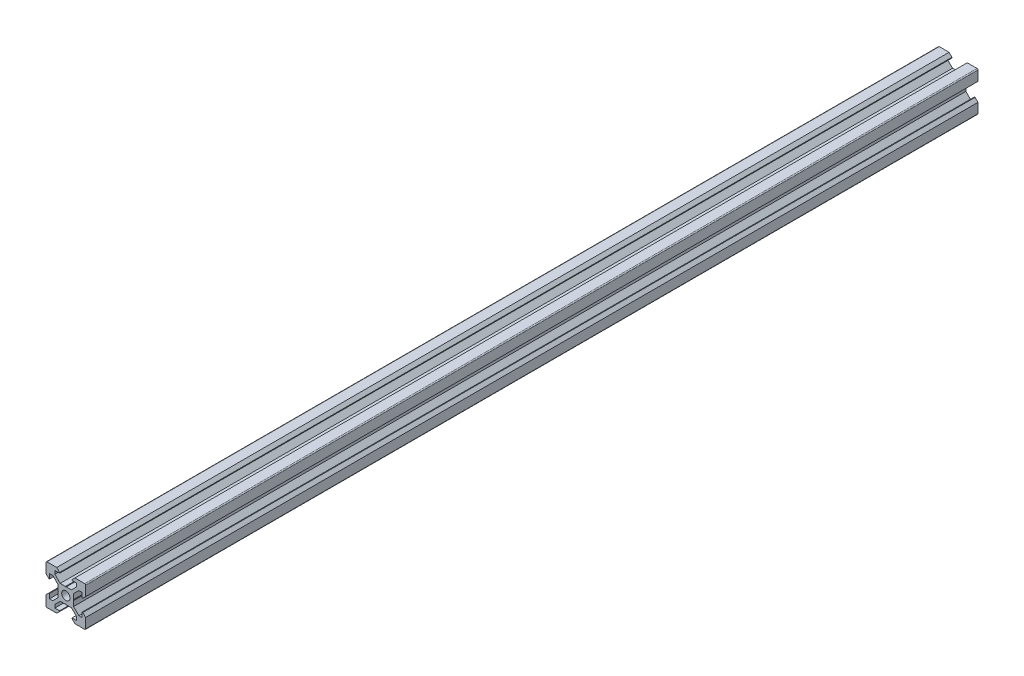
from build123d import *

# Parameters (mm, degrees)
SKETCH1_R           = 2.1
BOSS_EXTRUDE1_DEPTH = 450


with BuildPart() as part:
    # Sketch1 → Boss-Extrude1 (new body)
    with BuildSketch(Plane.XY):
        with BuildLine():
            Line((4.58, -10), (9.5, -10))
            ThreePointArc((9.5, -10), (9.853553391, -9.853553391), (10, -9.5))
            Line((10, -9.5), (10, -4.58))
            Line((10, -4.58), (8.545, -3.125))
            Line((8.545, -3.125), (8.2, -3.125))
            Line((8.2, -3.125), (8.2, -5.5))
            Line((8.2, -5.5), (6.560660172, -5.5))
            Line((6.560660172, -5.5), (3.9, -2.839339828))
            Line((3.9, -2.839339828), (3.9, -0.21))
            Line((3.9, -0.21), (3.69, 0))
            Line((3.69, 0), (3.9, 0.21))
            Line((3.9, 0.21), (3.9, 2.839339828))
            Line((3.9, 2.839339828), (6.560660172, 5.5))
            Line((6.560660172, 5.5), (8.2, 5.5))
            Line((8.2, 5.5), (8.2, 3.125))
            Line((8.2, 3.125), (8.545, 3.125))
            Line((8.545, 3.125), (10, 4.58))
            Line((10, 4.58), (10, 9.5))
            ThreePointArc((10, 9.5), (9.853553391, 9.853553391), (9.5, 10))
            Line((9.5, 10), (4.58, 10))
            Line((4.58, 10), (3.125, 8.545))
            Line((3.125, 8.545), (3.125, 8.2))
            Line((3.125, 8.2), (5.5, 8.2))
            Line((5.5, 8.2), (5.5, 6.560660172))
            Line((5.5, 6.560660172), (2.839339828, 3.9))
            Line((2.839339828, 3.9), (0.21, 3.9))
            Line((0.21, 3.9), (0, 3.69))
            Line((0, 3.69), (-0.21, 3.9))
            Line((-0.21, 3.9), (-2.839339828, 3.9))
            Line((-2.839339828, 3.9), (-5.5, 6.560660172))
            Line((-5.5, 6.560660172), (-5.5, 8.2))
            Line((-5.5, 8.2), (-3.125, 8.2))
            Line((-3.125, 8.2), (-3.125, 8.545))
            Line((-3.125, 8.545), (-4.58, 10))
            Line((-4.58, 10), (-9.5, 10))
            ThreePointArc((-9.5, 10), (-9.853553391, 9.853553391), (-10, 9.5))
            Line((-10, 9.5), (-10, 4.58))
            Line((-10, 4.58), (-8.545, 3.125))
            Line((-8.545, 3.125), (-8.2, 3.125))
            Line((-8.2, 3.125), (-8.2, 5.5))
            Line((-8.2, 5.5), (-6.560660172, 5.5))
            Line((-6.560660172, 5.5), (-3.9, 2.839339828))
            Line((-3.9, 2.839339828), (-3.9, 0.21))
            Line((-3.9, 0.21), (-3.69, 0))
            Line((-3.69, 0), (-3.9, -0.21))
            Line((-3.9, -0.21), (-3.9, -2.839339828))
            Line((-3.9, -2.839339828), (-6.560660172, -5.5))
            Line((-6.560660172, -5.5), (-8.2, -5.5))
            Line((-8.2, -5.5), (-8.2, -3.125))
            Line((-8.2, -3.125), (-8.545, -3.125))
            Line((-8.545, -3.125), (-10, -4.58))
            Line((-10, -4.58), (-10, -9.5))
            ThreePointArc((-10, -9.5), (-9.853553391, -9.853553391), (-9.5, -10))
            Line((-9.5, -10), (-4.58, -10))
            Line((-4.58, -10), (-3.125, -8.545))
            Line((-3.125, -8.545), (-3.125, -8.2))
            Line((-3.125, -8.2), (-5.5, -8.2))
            Line((-5.5, -8.2), (-5.5, -6.560660172))
            Line((-5.5, -6.560660172), (-2.839339828, -3.9))
            Line((-2.839339828, -3.9), (-0.21, -3.9))
            Line((-0.21, -3.9), (0, -3.69))
            Line((0, -3.69), (0.21, -3.9))
            Line((0.21, -3.9), (2.839339828, -3.9))
            Line((2.839339828, -3.9), (5.5, -6.560660172))
            Line((5.5, -6.560660172), (5.5, -8.2))
            Line((5.5, -8.2), (3.125, -8.2))
            Line((3.125, -8.2), (3.125, -8.545))
            Line((3.125, -8.545), (4.58, -10))
        make_face()
        Circle(SKETCH1_R, mode=Mode.SUBTRACT)
    extrude(amount=BOSS_EXTRUDE1_DEPTH)


solid = part.part
